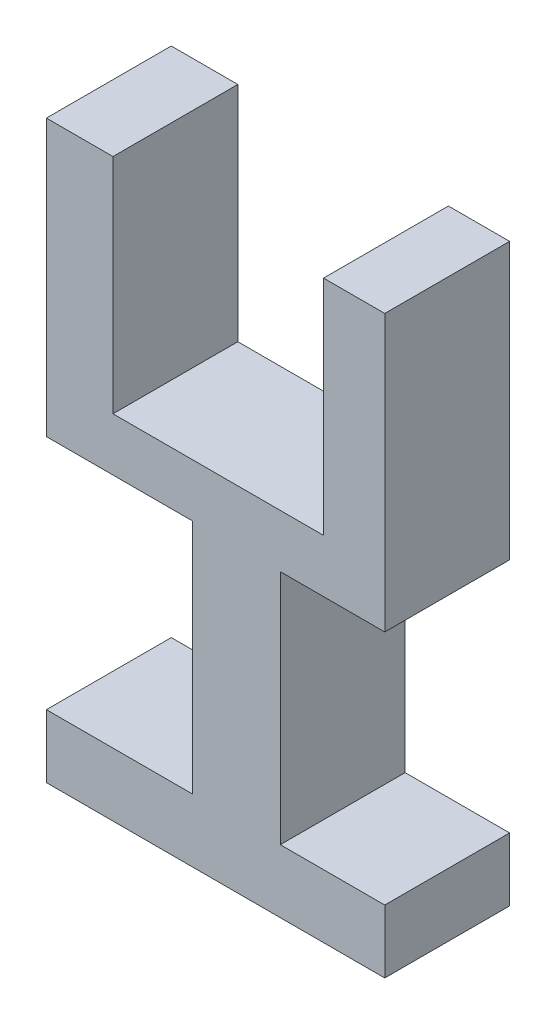
from build123d import *

# Parameters (mm, degrees)
BOSS_EXTRUDE1_DEPTH = 28


with BuildPart() as part:
    # Sketch2 → Boss-Extrude1 (new body)
    with BuildSketch(Plane.XY):
        Polygon((-37.524294488, 34.687091734), (-37.524294488, -15.284285804), (9.701402965, -15.284285804), (9.701402965, 34.687091734), (23.429803388, 34.687091734), (23.429803388, -27.182232837), (0, -27.182232837), (0, -80.216465931), (23.429803388, -80.216465931), (23.429803388, -94.393137067), (-52.459007625, -94.393137067), (-52.459007625, -80.216465931), (-19.642639255, -80.216465931), (-19.642639255, -27.182232837), (-52.459007625, -27.182232837), (-52.459007625, 34.687091734), align=None)
    extrude(amount=BOSS_EXTRUDE1_DEPTH)


solid = part.part
